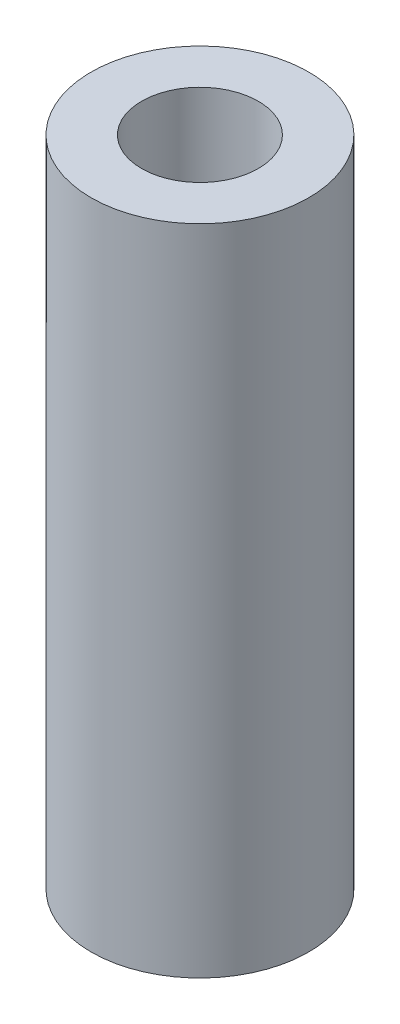
from build123d import *

# Parameters (mm, degrees)
SKETCH1_R           = 4.7625
SKETCH1_R_2         = 2.5527
BOSS_EXTRUDE1_DEPTH = 14.2875


with BuildPart() as part:
    # Sketch1 → Boss-Extrude1 (new body, symmetric)
    with BuildSketch(Plane(origin=(0, 0, 0), x_dir=(1, 0, 0), z_dir=(0, 1, 0))):
        Circle(SKETCH1_R)
        Circle(SKETCH1_R_2, mode=Mode.SUBTRACT)
    extrude(amount=BOSS_EXTRUDE1_DEPTH, both=True)


solid = part.part
